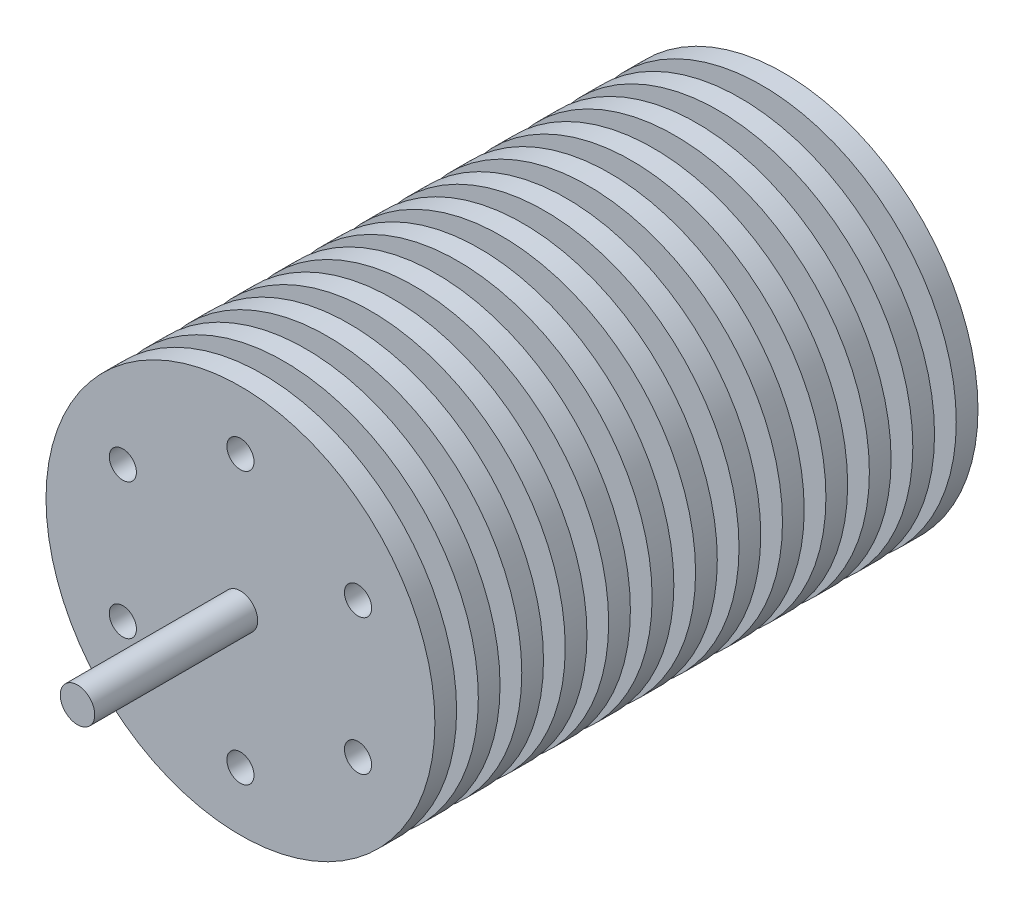
from build123d import *

# Parameters (mm, degrees)
SKETCH1_R                   = 17.9
BOSS_EXTRUDE1_DEPTH         = 50
BOSS_EXTRUDE2_START         = 50
SKETCH1_3_R                 = 1.5875
BOSS_EXTRUDE2_DEPTH         = 15
TAP_DRILL_FOR_M3_TAP1_D     = 2.5
TAP_DRILL_FOR_M3_TAP1_DEPTH = 5
TAP_DRILL_FOR_M3_TAP1_TIP   = 0.751075774
SKETCH6_W                   = 2
SKETCH6_H                   = 3


with BuildPart() as part:
    # Sketch1 → Boss-Extrude1 (new body)
    with BuildSketch(Plane.XY):
        Circle(SKETCH1_R)
    extrude(amount=BOSS_EXTRUDE1_DEPTH)

    # Sketch1_3 → Boss-Extrude2 (add)
    with BuildSketch(Plane.XY.offset(BOSS_EXTRUDE2_START)):
        Circle(SKETCH1_3_R)
    extrude(amount=BOSS_EXTRUDE2_DEPTH)

    # Tap Drill for M3 Tap1
    with Locations(Plane.XY.offset(50)):
        with Locations((0, 12.5), (10.825317547, 6.25), (10.825317547, -6.25), (0, -12.5), (-10.825317547, -6.25), (-10.825317547, 6.25)):
            Hole(TAP_DRILL_FOR_M3_TAP1_D / 2, depth=TAP_DRILL_FOR_M3_TAP1_DEPTH)
            with Locations((0, 0, -(TAP_DRILL_FOR_M3_TAP1_DEPTH + TAP_DRILL_FOR_M3_TAP1_TIP / 2))):  # 118° drill point
                Cone(0, TAP_DRILL_FOR_M3_TAP1_D / 2, TAP_DRILL_FOR_M3_TAP1_TIP, mode=Mode.SUBTRACT)

    # Sketch6 → Cut-Revolve1 (revolve, cut)
    with BuildSketch(Plane(origin=(0, 0, 0), x_dir=(0, 0, -1), z_dir=(1, 0, 0))):
        with Locations((-47, 16.4)):
            Rectangle(SKETCH6_W, SKETCH6_H)
        with Locations((-43, 16.4)):
            Rectangle(SKETCH6_W, SKETCH6_H)
        with Locations((-39, 16.4)):
            Rectangle(SKETCH6_W, SKETCH6_H)
        with Locations((-35, 16.4)):
            Rectangle(SKETCH6_W, SKETCH6_H)
        with Locations((-31, 16.4)):
            Rectangle(SKETCH6_W, SKETCH6_H)
        with Locations((-27, 16.4)):
            Rectangle(SKETCH6_W, SKETCH6_H)
        with Locations((-23, 16.4)):
            Rectangle(SKETCH6_W, SKETCH6_H)
        with Locations((-19, 16.4)):
            Rectangle(SKETCH6_W, SKETCH6_H)
        with Locations((-15, 16.4)):
            Rectangle(SKETCH6_W, SKETCH6_H)
        with Locations((-11, 16.4)):
            Rectangle(SKETCH6_W, SKETCH6_H)
        with Locations((-7, 16.4)):
            Rectangle(SKETCH6_W, SKETCH6_H)
        with Locations((-3, 16.4)):
            Rectangle(SKETCH6_W, SKETCH6_H)
    revolve(axis=Axis((0, 0, -3.25), (0, 0, 1)), mode=Mode.SUBTRACT)


solid = part.part
